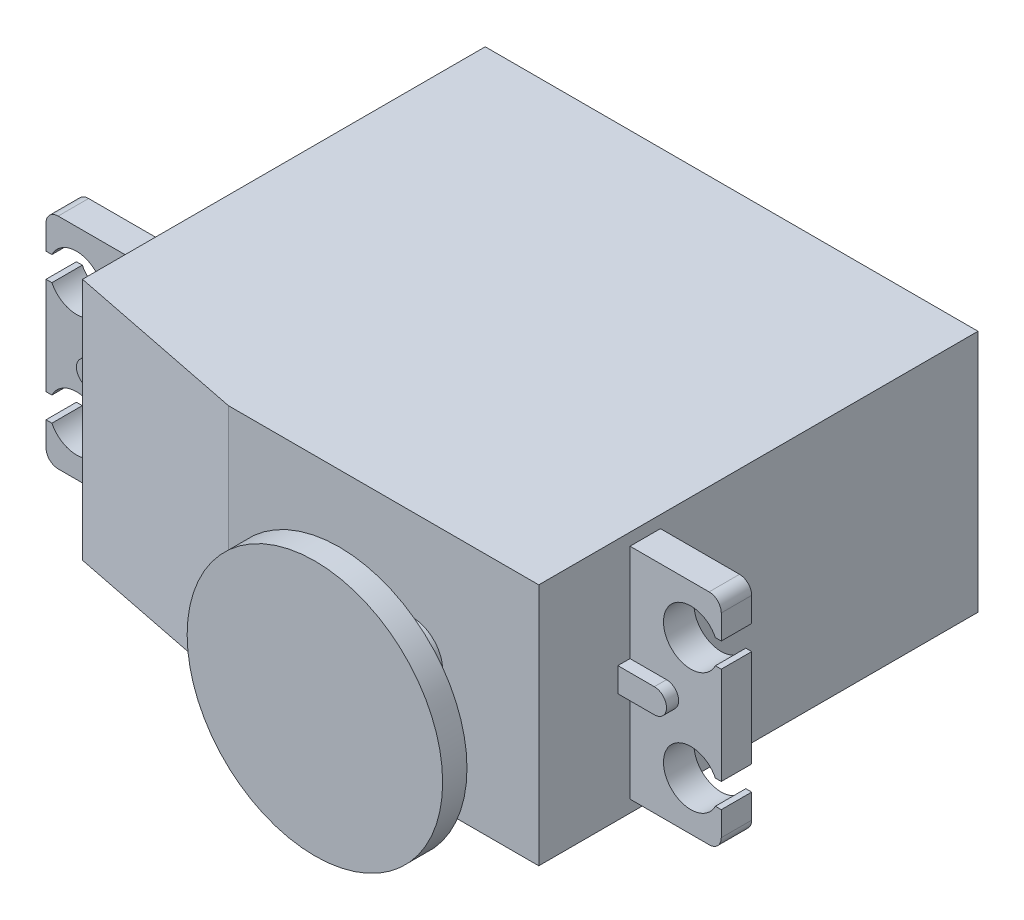
from build123d import *

# Parameters (mm, degrees)
SKETCH1_W            = 40.5
SKETCH1_H            = 20
BOSS_EXTRUDE1_DEPTH  = 36.1
BOSS_EXTRUDE2_DEPTH  = 2.5
BOSS_EXTRUDE3_DEPTH  = 1
FILLET1_R            = 1
FILLET1_OF_MIRROR1_R = 1
CHAMFER1_SIZE        = 3
CHAMFER1_SIZE2       = 15
SKETCH4_R            = 2.5
BOSS_EXTRUDE4_DEPTH  = 6
SKETCH5_R            = 10.5
BOSS_EXTRUDE5_DEPTH  = 2


with BuildPart() as part:
    # Sketch1 → Boss-Extrude1 (new body)
    with BuildSketch(Plane.XY):
        Rectangle(SKETCH1_W, SKETCH1_H)
    extrude(amount=BOSS_EXTRUDE1_DEPTH)

    # Sketch2 → Boss-Extrude2 (add)
    with BuildSketch(Plane(origin=(0, 0, 26.1), x_dir=(-1, 0, 0), z_dir=(0, 0, -1))):
        with BuildLine():
            Line((-20.25, 9), (-27.75, 9))
            Line((-27.75, 9), (-27.75, 6))
            Line((-27.75, 6), (-27.265564437, 6))
            ThreePointArc((-27.265564437, 6), (-23, 5), (-27.265564437, 4))
            Line((-27.265564437, 4), (-27.75, 4))
            Line((-27.75, 4), (-27.75, -4))
            Line((-27.75, -4), (-27.265564437, -4))
            ThreePointArc((-27.265564437, -4), (-23, -5), (-27.265564437, -6))
            Line((-27.265564437, -6), (-27.75, -6))
            Line((-27.75, -6), (-27.75, -9))
            Line((-27.75, -9), (-20.25, -9))
            Line((-20.25, -9), (-20.25, 9))
        make_face()
    boss_extrude2 = extrude(amount=-BOSS_EXTRUDE2_DEPTH)

    # Sketch3 → Boss-Extrude3 (add)
    with BuildSketch(Plane.XY.offset(28.6)):
        with BuildLine():
            Line((20.25, 1), (23.25, 1))
            ThreePointArc((23.25, 1), (24.25, 0), (23.25, -1))
            Line((23.25, -1), (20.25, -1))
            Line((20.25, -1), (20.25, 1))
        make_face()
    boss_extrude3 = extrude(amount=BOSS_EXTRUDE3_DEPTH)

    # Fillet1
    fillet1_edges = [part.edges().sort_by_distance(p)[0] for p in [
        (27.75, -9, 27.35),
        (27.75, 9, 27.35),
    ]]
    fillet(fillet1_edges, radius=FILLET1_R)

    # Mirror1: Boss-Extrude2, Boss-Extrude3 across plane
    add(boss_extrude2.mirror(Plane(origin=(0, 0, 0), x_dir=(0, 0, 1), z_dir=(1, 0, 0))))
    add(boss_extrude3.mirror(Plane(origin=(0, 0, 0), x_dir=(0, 0, 1), z_dir=(1, 0, 0))))

    # Fillet1 of Mirror1
    fillet1_of_mirror1_edges = [part.edges().sort_by_distance(p)[0] for p in [
        (-27.75, -9, 27.35),
        (-27.75, 9, 27.35),
    ]]
    fillet(fillet1_of_mirror1_edges, radius=FILLET1_OF_MIRROR1_R)

    # Chamfer1
    chamfer1_edges = [part.edges().sort_by_distance(p)[0] for p in [
        (-20.25, 0, 36.1),
    ]]
    chamfer1_side = [part.faces().sort_by_distance(p)[0] for p in [
        (-20.25, 0, 17.397259259),
    ]]
    chamfer(chamfer1_edges, length=CHAMFER1_SIZE, length2=CHAMFER1_SIZE2, reference=chamfer1_side[0])

    # Sketch4 → Boss-Extrude4 (add)
    with BuildSketch(Plane.XY.offset(36.1)):
        with Locations((9.85, 0)):
            Circle(SKETCH4_R)
    extrude(amount=BOSS_EXTRUDE4_DEPTH)

    # Sketch5 → Boss-Extrude5 (add)
    with BuildSketch(Plane.XY.offset(42.1)):
        with Locations((9.85, 0)):
            Circle(SKETCH5_R)
    extrude(amount=BOSS_EXTRUDE5_DEPTH)


solid = part.part
